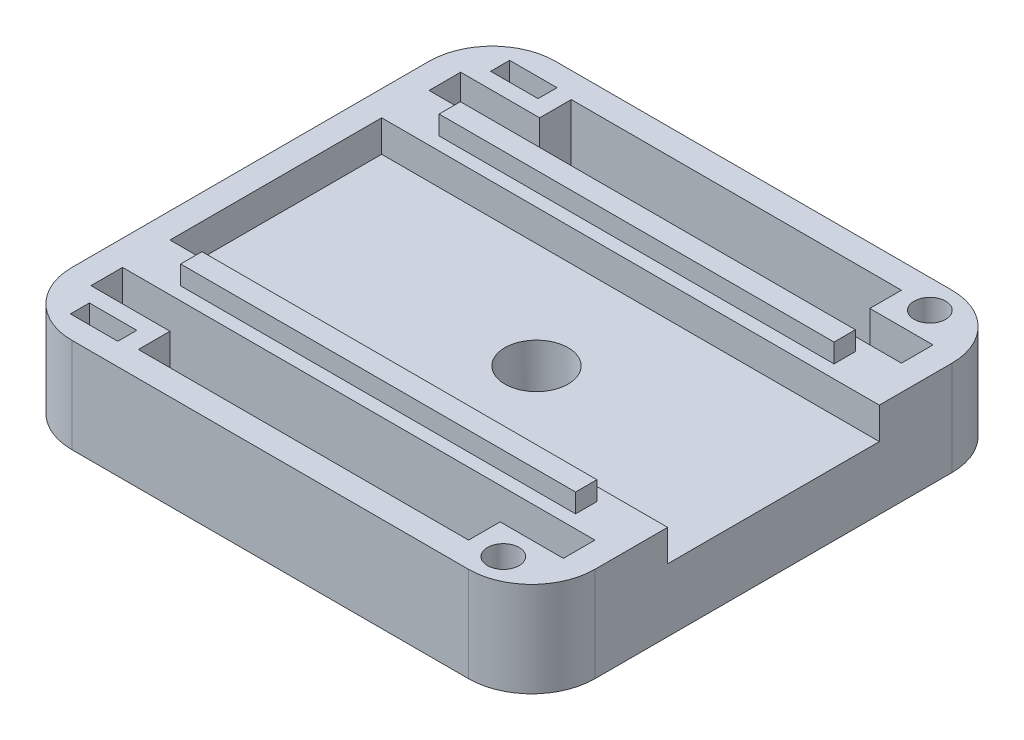
from build123d import *

# Parameters (mm, degrees)
BOSS_EXTRUDE1_DEPTH      = 5.08
BOSS_EXTRUDE1_DEPTH_BACK = 5.08
SKETCH1_W                = 84.074
SKETCH1_H                = 77.724
BOSS_EXTRUDE2_DEPTH      = 5.08
BOSS_EXTRUDE2_DEPTH_BACK = 10.16
SKETCH2_W                = 84.074
SKETCH2_H                = 77.724
CUT_EXTRUDE1_DEPTH       = 59.14284146
CUT_EXTRUDE1_DEPTH_BACK  = 59.14284146
SKETCH3_W                = 53.086
SKETCH3_H                = 5.08
CUT_EXTRUDE2_DEPTH       = 59.14284146
CUT_EXTRUDE2_DEPTH_BACK  = 59.14284146
SKETCH4_W                = 75.946
SKETCH4_H                = 5.08
BOSS_EXTRUDE3_DEPTH      = 5.08
BOSS_EXTRUDE3_DEPTH_BACK = 10.16
SKETCH5_W                = 75.946
SKETCH5_H                = 7.62
CUT_EXTRUDE4_DEPTH       = 59.14284146
CUT_EXTRUDE4_DEPTH_BACK  = 59.14284146
SKETCH10_R               = 5.08
FILLET1_R                = 10.16
SKETCH14_W               = 63.5
SKETCH14_H               = 3.429
BOSS_EXTRUDE7_DEPTH      = 3.048
SKETCH15_R               = 2.54
SKETCH15_W               = 7.62
SKETCH15_H               = 3.048
CUT_EXTRUDE6_DEPTH       = 60.242062869
SKETCH7_W                = 34.036
SKETCH7_H                = 5.08
CUT_EXTRUDE7_DEPTH       = 90.923892309


with BuildPart() as part:
    # Sketch1 → Boss-Extrude1 (new, two sides: drawn at the far end of the back side and taken through both)
    with BuildSketch(Plane(origin=(0, 0, 0), x_dir=(1, 0, 0), z_dir=(0, 1, 0)).offset(-BOSS_EXTRUDE1_DEPTH_BACK)):
        Rectangle(SKETCH1_W, SKETCH1_H)
    extrude(amount=BOSS_EXTRUDE1_DEPTH + BOSS_EXTRUDE1_DEPTH_BACK)

    # Sketch2 → Boss-Extrude2 (add, two sides: drawn at the far end of the back side and taken through both)
    with BuildSketch(Plane(origin=(0, 5.08, 0), x_dir=(1, 0, 0), z_dir=(0, 1, 0)).offset(-BOSS_EXTRUDE2_DEPTH_BACK)):
        Rectangle(SKETCH2_W, SKETCH2_H)
        Polygon((-25.273, 34.798), (27.813, 34.798), (27.813, 29.718), (37.973, 29.718), (37.973, -29.718), (27.813, -29.718), (27.813, -34.798), (-25.273, -34.798), (-25.273, -29.718), (-37.973, -29.718), (-37.973, 29.718), (-25.273, 29.718), align=None, mode=Mode.SUBTRACT)
    extrude(amount=BOSS_EXTRUDE2_DEPTH + BOSS_EXTRUDE2_DEPTH_BACK)

    # Sketch3 → Cut-Extrude1 (cut, two sides: drawn at the far end of the back side and taken through both)
    with BuildSketch(Plane(origin=(0, 5.08, 0), x_dir=(1, 0, 0), z_dir=(0, 1, 0)).offset(-CUT_EXTRUDE1_DEPTH_BACK)):
        with Locations((1.27, 32.258)):
            Rectangle(SKETCH3_W, SKETCH3_H)
        with Locations((1.27, -32.258)):
            Rectangle(SKETCH3_W, SKETCH3_H)
    extrude(amount=CUT_EXTRUDE1_DEPTH + CUT_EXTRUDE1_DEPTH_BACK, mode=Mode.SUBTRACT)

    # Sketch4 → Cut-Extrude2 (cut, two sides: drawn at the far end of the back side and taken through both)
    with BuildSketch(Plane(origin=(0, 5.08, 0), x_dir=(1, 0, 0), z_dir=(0, 1, 0)).offset(-CUT_EXTRUDE2_DEPTH_BACK)):
        with Locations((0, 27.178)):
            Rectangle(SKETCH4_W, SKETCH4_H)
        with Locations((0, -27.178)):
            Rectangle(SKETCH4_W, SKETCH4_H)
    extrude(amount=CUT_EXTRUDE2_DEPTH + CUT_EXTRUDE2_DEPTH_BACK, mode=Mode.SUBTRACT)

    # Sketch5 → Boss-Extrude3 (add, two sides: drawn at the far end of the back side and taken through both)
    with BuildSketch(Plane(origin=(0, 5.08, 0), x_dir=(1, 0, 0), z_dir=(0, 1, 0)).offset(-BOSS_EXTRUDE3_DEPTH_BACK)):
        with Locations((0, 20.828)):
            Rectangle(SKETCH5_W, SKETCH5_H)
        with Locations((0, -20.828)):
            Rectangle(SKETCH5_W, SKETCH5_H)
    extrude(amount=BOSS_EXTRUDE3_DEPTH + BOSS_EXTRUDE3_DEPTH_BACK)

    # Sketch10 → Cut-Extrude4 (cut, two sides: drawn at the far end of the back side and taken through both)
    with BuildSketch(Plane(origin=(0, 5.08, 0), x_dir=(1, 0, 0), z_dir=(0, 1, 0)).offset(-CUT_EXTRUDE4_DEPTH_BACK)):
        with Locations((3.937, 0)):
            Circle(SKETCH10_R)
    extrude(amount=CUT_EXTRUDE4_DEPTH + CUT_EXTRUDE4_DEPTH_BACK, mode=Mode.SUBTRACT)

    # Fillet1
    fillet1_edges = [part.edges().sort_by_distance(p)[0] for p in [
        (42.037, 2.54, -38.862),
        (-42.037, 2.54, -38.862),
        (-42.037, 2.54, 38.862),
        (42.037, 2.54, 38.862),
    ]]
    fillet(fillet1_edges, radius=FILLET1_R)

    # Sketch14 → Boss-Extrude7 (add)
    with BuildSketch(Plane(origin=(0, 10.16, 0), x_dir=(1, 0, 0), z_dir=(0, 1, 0))):
        with Locations((1.015527002, -20.828)):
            Rectangle(SKETCH14_W, SKETCH14_H)
        with Locations((0.914410511, 20.828)):
            Rectangle(SKETCH14_W, SKETCH14_H)
    extrude(amount=BOSS_EXTRUDE7_DEPTH)

    # Sketch15 → Cut-Extrude6 (cut, symmetric)
    with BuildSketch(Plane(origin=(0, 10.16, 0), x_dir=(1, 0, 0), z_dir=(0, 1, 0))):
        with Locations((32.893, 34.29)):
            Circle(SKETCH15_R)
        with Locations((-31.877, 33.782)):
            Rectangle(SKETCH15_W, SKETCH15_H)
    cut_extrude6 = extrude(amount=CUT_EXTRUDE6_DEPTH, both=True, mode=Mode.SUBTRACT)

    # Mirror1: Cut-Extrude6 across plane
    add(cut_extrude6.mirror(Plane.XY), mode=Mode.SUBTRACT)

    # Sketch7 → Cut-Extrude7 (cut, through all)
    with BuildSketch(Plane.ZY.offset(-37.973)):
        with Locations((0, 7.62)):
            Rectangle(SKETCH7_W, SKETCH7_H)
    extrude(amount=-CUT_EXTRUDE7_DEPTH, mode=Mode.SUBTRACT)


solid = part.part
